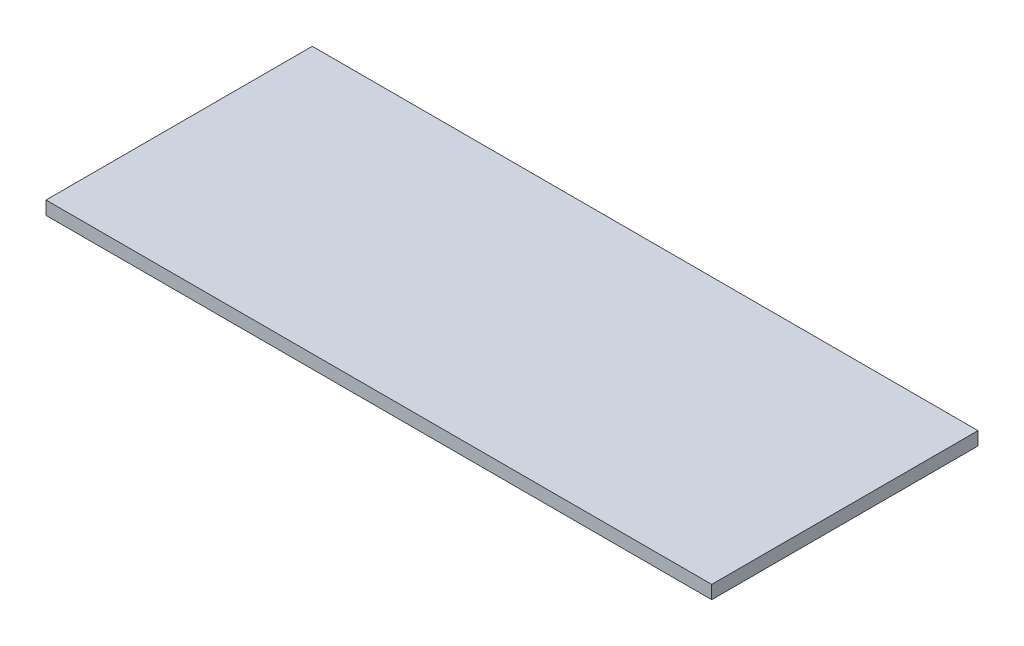
from build123d import *

# Parameters (mm, degrees)
SKETCH1_W           = 500
SKETCH1_H           = 200
BOSS_EXTRUDE1_DEPTH = 10


with BuildPart() as part:
    # Sketch1 → Boss-Extrude1 (new body)
    with BuildSketch(Plane(origin=(0, 0, 0), x_dir=(1, 0, 0), z_dir=(0, 1, 0))):
        Rectangle(SKETCH1_W, SKETCH1_H)
    extrude(amount=BOSS_EXTRUDE1_DEPTH)


solid = part.part
